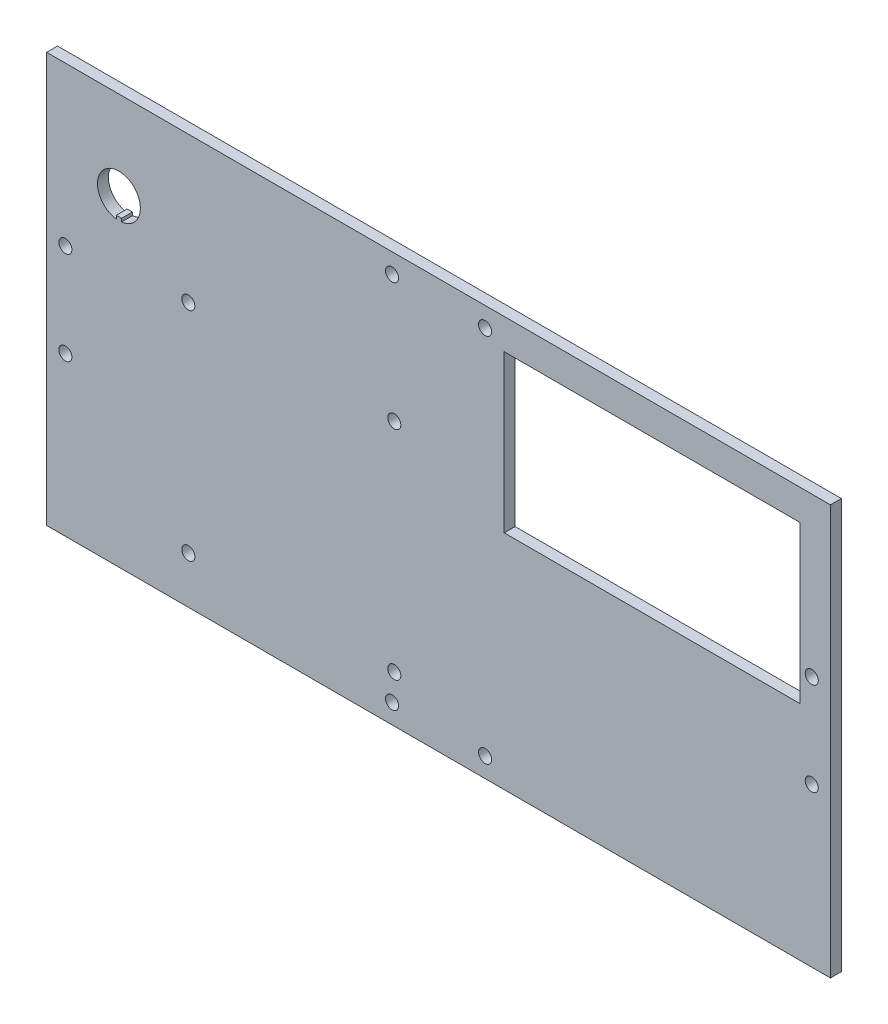
from build123d import *

# Parameters (mm, degrees)
SKETCH1_W           = 228.346
SKETCH1_H           = 119.38
SKETCH1_R           = 1.905
SKETCH1_W_2         = 86.15
SKETCH1_H_2         = 45.7
BOSS_EXTRUDE1_DEPTH = 3.175


with BuildPart() as part:
    # Sketch1 → Boss-Extrude1 (new body)
    with BuildSketch(Plane.XY):
        Rectangle(SKETCH1_W, SKETCH1_H)
        with Locations((-72.898, -46.017112716)):
            Circle(SKETCH1_R, mode=Mode.SUBTRACT)
        with Locations((-13.5509, -53.975)):
            Circle(SKETCH1_R, mode=Mode.SUBTRACT)
        with Locations((-12.898, -46.017112716)):
            Circle(SKETCH1_R, mode=Mode.SUBTRACT)
        with Locations((-108.72089, -13.5509)):
            Circle(SKETCH1_R, mode=Mode.SUBTRACT)
        with Locations((13.5509, -53.975)):
            Circle(SKETCH1_R, mode=Mode.SUBTRACT)
        with Locations((108.72089, -13.5509)):
            Circle(SKETCH1_R, mode=Mode.SUBTRACT)
        with Locations((-108.72089, 13.5509)):
            Circle(SKETCH1_R, mode=Mode.SUBTRACT)
        with Locations((-72.898, 17.232887284)):
            Circle(SKETCH1_R, mode=Mode.SUBTRACT)
        with Locations((-12.898, 17.232887284)):
            Circle(SKETCH1_R, mode=Mode.SUBTRACT)
        with BuildLine():
            Line((-92.353861631, 27.78117125), (-92.353861631, 28.725133786))
            Line((-92.353861631, 28.725133786), (-93.877861631, 28.725133786))
            Line((-93.877861631, 28.725133786), (-93.877861631, 27.78117125))
            ThreePointArc((-93.877861631, 27.78117125), (-93.115861631, 40.231333786), (-92.353861631, 27.78117125))
        make_face(mode=Mode.SUBTRACT)
        with Locations((-13.5509, 53.975)):
            Circle(SKETCH1_R, mode=Mode.SUBTRACT)
        with Locations((108.72089, 13.5509)):
            Circle(SKETCH1_R, mode=Mode.SUBTRACT)
        with Locations((62.208, 27.95)):
            Rectangle(SKETCH1_W_2, SKETCH1_H_2, mode=Mode.SUBTRACT)
        with Locations((13.5509, 53.975)):
            Circle(SKETCH1_R, mode=Mode.SUBTRACT)
    extrude(amount=BOSS_EXTRUDE1_DEPTH)


solid = part.part
